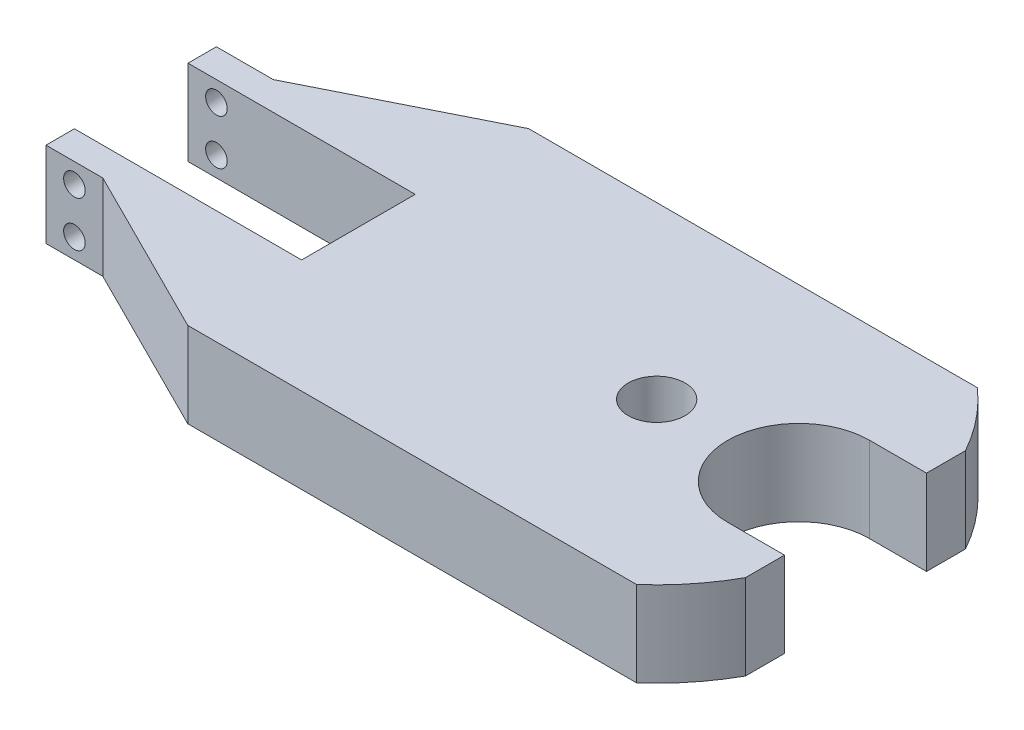
from build123d import *

# Parameters (mm, degrees)
SKETCH1_R           = 0.5
BOSS_EXTRUDE1_DEPTH = 0.75
SKETCH2_R           = 0.19
CUT_EXTRUDE1_DEPTH  = 5.5
SKETCH3_R           = 0.375
CUT_EXTRUDE2_DEPTH  = 0.75


with BuildPart() as part:
    # Sketch1 → Boss-Extrude1 (new body, symmetric)
    with BuildSketch(Plane(origin=(0, 0, 0), x_dir=(1, 0, 0), z_dir=(0, 1, 0))):
        with BuildLine():
            Line((0, 1), (-4, 1))
            Line((-4, 1), (-4, 1.5))
            Line((-4, 1.5), (-3, 1.5))
            Line((-3, 1.5), (-0.00458684, 3))
            Line((-0.00458684, 3), (7.895751311, 3))
            ThreePointArc((7.895751311, 3), (8.3685457, 2.504929683), (8.75, 1.936491673))
            Line((8.75, 1.936491673), (8.75, 1.25))
            Line((8.75, 1.25), (7.75, 1.25))
            ThreePointArc((7.75, 1.25), (6.5, 0), (7.75, -1.25))
            Line((7.75, -1.25), (8.75, -1.25))
            Line((8.75, -1.25), (8.75, -1.936491673))
            ThreePointArc((8.75, -1.936491673), (8.3685457, -2.504929683), (7.895751311, -3))
            Line((7.895751311, -3), (-0.00458684, -3))
            Line((-0.00458684, -3), (-3, -1.5))
            Line((-3, -1.5), (-4, -1.5))
            Line((-4, -1.5), (-4, -1))
            Line((-4, -1), (0, -1))
            Line((0, -1), (0, 1))
        make_face()
        with Locations((5.25, 0)):
            Circle(SKETCH1_R, mode=Mode.SUBTRACT)
    extrude(amount=BOSS_EXTRUDE1_DEPTH, both=True)

    # Sketch2 → Cut-Extrude1 (cut, through all)
    with BuildSketch(Plane.XY.offset(1.5)):
        with Locations((-3.5, 0.4)):
            Circle(SKETCH2_R)
        with Locations((-3.5, -0.4)):
            Circle(SKETCH2_R)
    extrude(amount=-CUT_EXTRUDE1_DEPTH, mode=Mode.SUBTRACT)

    # Sketch3 → Cut-Extrude2 (cut)
    with BuildSketch(Plane.ZY):
        Circle(SKETCH3_R)
    extrude(amount=-CUT_EXTRUDE2_DEPTH, mode=Mode.SUBTRACT)


solid = part.part
